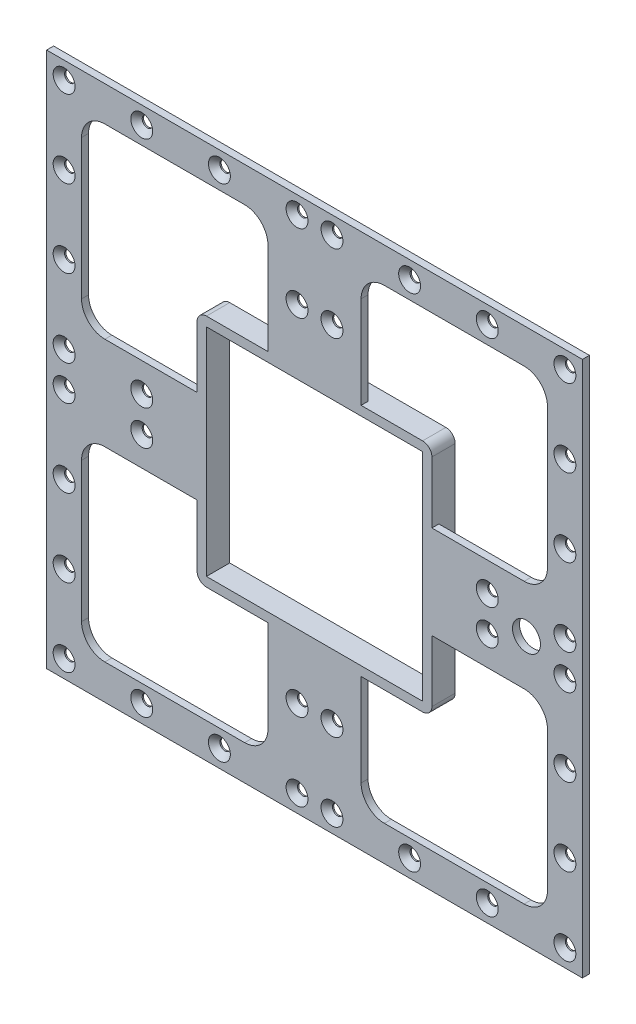
from build123d import *

# Parameters (mm, degrees)
SKETCH1_W              = 230
SKETCH1_H              = 230
BOSS_EXTRUDE1_DEPTH    = 3
SKETCH2_W              = 80
SKETCH2_H              = 80
CUT_EXTRUDE2_DEPTH     = 4
FILLET1_R              = 10
LPATTERN2_COUNT        = 2
LPATTERN2_PITCH        = 120
LPATTERN2_COUNT_DIR2   = 2
LPATTERN2_PITCH_DIR2   = 120
FILLET1_OF_LPATTERN2_R = 10
LPATTERN8_COUNT        = 4
LPATTERN8_PITCH        = 33.333333333
LPATTERN8_COUNT_DIR2   = 4
LPATTERN8_PITCH_DIR2   = 33.333333333
CUT_EXTRUDE3_REACH     = 5
SKETCH14_W             = 98
SKETCH14_H             = 98
SKETCH15_W             = 100.8
SKETCH15_H             = 100.8
SKETCH15_W_2           = 92.8
SKETCH15_H_2           = 92.8
BOSS_EXTRUDE2_DEPTH    = 10
FILLET2_R              = 4
CUT_EXTRUDE4_REACH     = 12
SKETCH16_R             = 6


with BuildPart() as part:
    # Sketch1 → Boss-Extrude1 (new body)
    with BuildSketch(Plane.XY):
        Rectangle(SKETCH1_W, SKETCH1_H)
    extrude(amount=BOSS_EXTRUDE1_DEPTH)

    # Sketch2 → Cut-Extrude2 (cut, through all)
    with BuildSketch(Plane.XY):
        with Locations((-60, 60)):
            Rectangle(SKETCH2_W, SKETCH2_H)
    cut_extrude2 = extrude(amount=CUT_EXTRUDE2_DEPTH, mode=Mode.SUBTRACT)

    # Fillet1
    fillet1_edges = [part.edges().sort_by_distance(p)[0] for p in [
        (-20, 20, 1.5),
        (-20, 100, 1.5),
        (-100, 100, 1.5),
        (-100, 20, 1.5),
    ]]
    fillet(fillet1_edges, radius=FILLET1_R)

    # LPattern2: Cut-Extrude2 2 × 2
    with Locations(*[(j * LPATTERN2_PITCH_DIR2, -i * LPATTERN2_PITCH, 0) for i in range(LPATTERN2_COUNT) for j in range(LPATTERN2_COUNT_DIR2) if (i, j) != (0, 0)]):
        add(cut_extrude2, mode=Mode.SUBTRACT)

    # Fillet1 of LPattern2
    fillet1_of_lpattern2_edges = [part.edges().sort_by_distance(p)[0] for p in [
        (100, 20, 1.5),
        (100, 100, 1.5),
        (20, 100, 1.5),
        (20, 20, 1.5),
        (-20, -100, 1.5),
        (-20, -20, 1.5),
        (-100, -20, 1.5),
        (-100, -100, 1.5),
        (100, -100, 1.5),
        (100, -20, 1.5),
        (20, -20, 1.5),
        (20, -100, 1.5),
    ]]
    fillet(fillet1_of_lpattern2_edges, radius=FILLET1_OF_LPATTERN2_R)

    # Sketch12 → CSK for M4 Flat Head Machine Screw4 (revolve, cut)
    with BuildSketch(Plane(origin=(-107.5, 107.5, 3), x_dir=(0, -1, 0), z_dir=(1, 0, 0))):
        Polygon((0, 0), (0, 3), (2.25, 3), (2.25, 2.45), (4.7, 0), align=None)
    csk_for_m4_flat_head_machine_screw4 = revolve(axis=Axis((-107.5, 107.5, 9.35), (0, 0, -1)), mode=Mode.SUBTRACT)

    # LPattern8: CSK for M4 Flat Head Machine Screw4 4 × 4, 4 skipped
    with Locations(*[(i * LPATTERN8_PITCH, -j * LPATTERN8_PITCH_DIR2, 0) for i in range(LPATTERN8_COUNT) for j in range(LPATTERN8_COUNT_DIR2) if (i, j) not in ((0, 0), (1, 1), (1, 2), (2, 1), (2, 2))]):
        add(csk_for_m4_flat_head_machine_screw4, mode=Mode.SUBTRACT)

    # Mirror1: CSK for M4 Flat Head Machine Screw4 across plane
    add(csk_for_m4_flat_head_machine_screw4.mirror(Plane(origin=(0, 0, 0), x_dir=(0, 0, 1), z_dir=(1, 0, 0))), mode=Mode.SUBTRACT)

    # Mirror1 copy 1 sketch → Mirror1 copy 1 (revolve, cut)
    with BuildSketch(Plane(origin=(107.5, 74.166666667, 3), x_dir=(0, -1, 0), z_dir=(-1, 0, 0))):
        Polygon((0, 0), (0, -3), (2.25, -3), (2.25, -2.45), (4.7, 0), align=None)
    revolve(axis=Axis((107.5, 74.166666667, 9.35), (0, 0, 1)), mode=Mode.SUBTRACT)

    # Mirror1 copy 2 sketch → Mirror1 copy 2 (revolve, cut)
    with BuildSketch(Plane(origin=(107.5, 40.833333333, 3), x_dir=(0, -1, 0), z_dir=(-1, 0, 0))):
        Polygon((0, 0), (0, -3), (2.25, -3), (2.25, -2.45), (4.7, 0), align=None)
    revolve(axis=Axis((107.5, 40.833333333, 9.35), (0, 0, 1)), mode=Mode.SUBTRACT)

    # Mirror1 copy 3 sketch → Mirror1 copy 3 (revolve, cut)
    with BuildSketch(Plane(origin=(107.5, 7.5, 3), x_dir=(0, -1, 0), z_dir=(-1, 0, 0))):
        Polygon((0, 0), (0, -3), (2.25, -3), (2.25, -2.45), (4.7, 0), align=None)
    revolve(axis=Axis((107.5, 7.5, 9.35), (0, 0, 1)), mode=Mode.SUBTRACT)

    # Mirror1 copy 4 sketch → Mirror1 copy 4 (revolve, cut)
    with BuildSketch(Plane(origin=(74.166666667, 107.5, 3), x_dir=(0, -1, 0), z_dir=(-1, 0, 0))):
        Polygon((0, 0), (0, -3), (2.25, -3), (2.25, -2.45), (4.7, 0), align=None)
    revolve(axis=Axis((74.166666667, 107.5, 9.35), (0, 0, 1)), mode=Mode.SUBTRACT)

    # Mirror1 copy 5 sketch → Mirror1 copy 5 (revolve, cut)
    with BuildSketch(Plane(origin=(74.166666667, 7.5, 3), x_dir=(0, -1, 0), z_dir=(-1, 0, 0))):
        Polygon((0, 0), (0, -3), (2.25, -3), (2.25, -2.45), (4.7, 0), align=None)
    revolve(axis=Axis((74.166666667, 7.5, 9.35), (0, 0, 1)), mode=Mode.SUBTRACT)

    # Mirror1 copy 6 sketch → Mirror1 copy 6 (revolve, cut)
    with BuildSketch(Plane(origin=(40.833333333, 107.5, 3), x_dir=(0, -1, 0), z_dir=(-1, 0, 0))):
        Polygon((0, 0), (0, -3), (2.25, -3), (2.25, -2.45), (4.7, 0), align=None)
    revolve(axis=Axis((40.833333333, 107.5, 9.35), (0, 0, 1)), mode=Mode.SUBTRACT)

    # Mirror1 copy 7 sketch → Mirror1 copy 7 (revolve, cut)
    with BuildSketch(Plane(origin=(40.833333333, 7.5, 3), x_dir=(0, -1, 0), z_dir=(-1, 0, 0))):
        Polygon((0, 0), (0, -3), (2.25, -3), (2.25, -2.45), (4.7, 0), align=None)
    revolve(axis=Axis((40.833333333, 7.5, 9.35), (0, 0, 1)), mode=Mode.SUBTRACT)

    # Mirror1 copy 8 sketch → Mirror1 copy 8 (revolve, cut)
    with BuildSketch(Plane(origin=(7.5, 107.5, 3), x_dir=(0, -1, 0), z_dir=(-1, 0, 0))):
        Polygon((0, 0), (0, -3), (2.25, -3), (2.25, -2.45), (4.7, 0), align=None)
    revolve(axis=Axis((7.5, 107.5, 9.35), (0, 0, 1)), mode=Mode.SUBTRACT)

    # Mirror1 copy 9 sketch → Mirror1 copy 9 (revolve, cut)
    with BuildSketch(Plane(origin=(7.5, 74.166666667, 3), x_dir=(0, -1, 0), z_dir=(-1, 0, 0))):
        Polygon((0, 0), (0, -3), (2.25, -3), (2.25, -2.45), (4.7, 0), align=None)
    revolve(axis=Axis((7.5, 74.166666667, 9.35), (0, 0, 1)), mode=Mode.SUBTRACT)

    # Mirror1 copy 10 sketch → Mirror1 copy 10 (revolve, cut)
    with BuildSketch(Plane(origin=(7.5, 40.833333333, 3), x_dir=(0, -1, 0), z_dir=(-1, 0, 0))):
        Polygon((0, 0), (0, -3), (2.25, -3), (2.25, -2.45), (4.7, 0), align=None)
    revolve(axis=Axis((7.5, 40.833333333, 9.35), (0, 0, 1)), mode=Mode.SUBTRACT)

    # Mirror1 copy 11 sketch → Mirror1 copy 11 (revolve, cut)
    with BuildSketch(Plane(origin=(7.5, 7.5, 3), x_dir=(0, -1, 0), z_dir=(-1, 0, 0))):
        Polygon((0, 0), (0, -3), (2.25, -3), (2.25, -2.45), (4.7, 0), align=None)
    revolve(axis=Axis((7.5, 7.5, 9.35), (0, 0, 1)), mode=Mode.SUBTRACT)

    # Mirror1 at the second plane: CSK for M4 Flat Head Machine Screw4 across plane
    add(csk_for_m4_flat_head_machine_screw4.mirror(Plane.ZX), mode=Mode.SUBTRACT)

    # Mirror1 at the second plane copy 1 sketc → Mirror1 at the second plane copy 1 (revolve, cut)
    with BuildSketch(Plane(origin=(-107.5, -74.166666667, 3), x_dir=(0, 1, 0), z_dir=(1, 0, 0))):
        Polygon((0, 0), (0, -3), (2.25, -3), (2.25, -2.45), (4.7, 0), align=None)
    revolve(axis=Axis((-107.5, -74.166666667, 9.35), (0, 0, 1)), mode=Mode.SUBTRACT)

    # Mirror1 at the second plane copy 2 sketc → Mirror1 at the second plane copy 2 (revolve, cut)
    with BuildSketch(Plane(origin=(-107.5, -40.833333333, 3), x_dir=(0, 1, 0), z_dir=(1, 0, 0))):
        Polygon((0, 0), (0, -3), (2.25, -3), (2.25, -2.45), (4.7, 0), align=None)
    revolve(axis=Axis((-107.5, -40.833333333, 9.35), (0, 0, 1)), mode=Mode.SUBTRACT)

    # Mirror1 at the second plane copy 3 sketc → Mirror1 at the second plane copy 3 (revolve, cut)
    with BuildSketch(Plane(origin=(-107.5, -7.5, 3), x_dir=(0, 1, 0), z_dir=(1, 0, 0))):
        Polygon((0, 0), (0, -3), (2.25, -3), (2.25, -2.45), (4.7, 0), align=None)
    revolve(axis=Axis((-107.5, -7.5, 9.35), (0, 0, 1)), mode=Mode.SUBTRACT)

    # Mirror1 at the second plane copy 4 sketc → Mirror1 at the second plane copy 4 (revolve, cut)
    with BuildSketch(Plane(origin=(-74.166666667, -107.5, 3), x_dir=(0, 1, 0), z_dir=(1, 0, 0))):
        Polygon((0, 0), (0, -3), (2.25, -3), (2.25, -2.45), (4.7, 0), align=None)
    revolve(axis=Axis((-74.166666667, -107.5, 9.35), (0, 0, 1)), mode=Mode.SUBTRACT)

    # Mirror1 at the second plane copy 5 sketc → Mirror1 at the second plane copy 5 (revolve, cut)
    with BuildSketch(Plane(origin=(-74.166666667, -7.5, 3), x_dir=(0, 1, 0), z_dir=(1, 0, 0))):
        Polygon((0, 0), (0, -3), (2.25, -3), (2.25, -2.45), (4.7, 0), align=None)
    revolve(axis=Axis((-74.166666667, -7.5, 9.35), (0, 0, 1)), mode=Mode.SUBTRACT)

    # Mirror1 at the second plane copy 6 sketc → Mirror1 at the second plane copy 6 (revolve, cut)
    with BuildSketch(Plane(origin=(-40.833333333, -107.5, 3), x_dir=(0, 1, 0), z_dir=(1, 0, 0))):
        Polygon((0, 0), (0, -3), (2.25, -3), (2.25, -2.45), (4.7, 0), align=None)
    revolve(axis=Axis((-40.833333333, -107.5, 9.35), (0, 0, 1)), mode=Mode.SUBTRACT)

    # Mirror1 at the second plane copy 7 sketc → Mirror1 at the second plane copy 7 (revolve, cut)
    with BuildSketch(Plane(origin=(-40.833333333, -7.5, 3), x_dir=(0, 1, 0), z_dir=(1, 0, 0))):
        Polygon((0, 0), (0, -3), (2.25, -3), (2.25, -2.45), (4.7, 0), align=None)
    revolve(axis=Axis((-40.833333333, -7.5, 9.35), (0, 0, 1)), mode=Mode.SUBTRACT)

    # Mirror1 at the second plane copy 8 sketc → Mirror1 at the second plane copy 8 (revolve, cut)
    with BuildSketch(Plane(origin=(-7.5, -107.5, 3), x_dir=(0, 1, 0), z_dir=(1, 0, 0))):
        Polygon((0, 0), (0, -3), (2.25, -3), (2.25, -2.45), (4.7, 0), align=None)
    revolve(axis=Axis((-7.5, -107.5, 9.35), (0, 0, 1)), mode=Mode.SUBTRACT)

    # Mirror1 at the second plane copy 9 sketc → Mirror1 at the second plane copy 9 (revolve, cut)
    with BuildSketch(Plane(origin=(-7.5, -74.166666667, 3), x_dir=(0, 1, 0), z_dir=(1, 0, 0))):
        Polygon((0, 0), (0, -3), (2.25, -3), (2.25, -2.45), (4.7, 0), align=None)
    revolve(axis=Axis((-7.5, -74.166666667, 9.35), (0, 0, 1)), mode=Mode.SUBTRACT)

    # Mirror1 at the second plane copy 10 sket → Mirror1 at the second plane copy 10 (revolve, cut)
    with BuildSketch(Plane(origin=(-7.5, -40.833333333, 3), x_dir=(0, 1, 0), z_dir=(1, 0, 0))):
        Polygon((0, 0), (0, -3), (2.25, -3), (2.25, -2.45), (4.7, 0), align=None)
    revolve(axis=Axis((-7.5, -40.833333333, 9.35), (0, 0, 1)), mode=Mode.SUBTRACT)

    # Mirror1 at the second plane copy 11 sket → Mirror1 at the second plane copy 11 (revolve, cut)
    with BuildSketch(Plane(origin=(-7.5, -7.5, 3), x_dir=(0, 1, 0), z_dir=(1, 0, 0))):
        Polygon((0, 0), (0, -3), (2.25, -3), (2.25, -2.45), (4.7, 0), align=None)
    revolve(axis=Axis((-7.5, -7.5, 9.35), (0, 0, 1)), mode=Mode.SUBTRACT)

    # Mirror1 at the second plane copy 12 sket → Mirror1 at the second plane copy 12 (revolve, cut)
    with BuildSketch(Plane(origin=(107.5, -107.5, 3), x_dir=(0, 1, 0), z_dir=(-1, 0, 0))):
        Polygon((0, 0), (0, 3), (2.25, 3), (2.25, 2.45), (4.7, 0), align=None)
    revolve(axis=Axis((107.5, -107.5, 9.35), (0, 0, -1)), mode=Mode.SUBTRACT)

    # Mirror1 at the second plane copy 13 sket → Mirror1 at the second plane copy 13 (revolve, cut)
    with BuildSketch(Plane(origin=(107.5, -74.166666667, 3), x_dir=(0, 1, 0), z_dir=(-1, 0, 0))):
        Polygon((0, 0), (0, 3), (2.25, 3), (2.25, 2.45), (4.7, 0), align=None)
    revolve(axis=Axis((107.5, -74.166666667, 9.35), (0, 0, -1)), mode=Mode.SUBTRACT)

    # Mirror1 at the second plane copy 14 sket → Mirror1 at the second plane copy 14 (revolve, cut)
    with BuildSketch(Plane(origin=(107.5, -40.833333333, 3), x_dir=(0, 1, 0), z_dir=(-1, 0, 0))):
        Polygon((0, 0), (0, 3), (2.25, 3), (2.25, 2.45), (4.7, 0), align=None)
    revolve(axis=Axis((107.5, -40.833333333, 9.35), (0, 0, -1)), mode=Mode.SUBTRACT)

    # Mirror1 at the second plane copy 15 sket → Mirror1 at the second plane copy 15 (revolve, cut)
    with BuildSketch(Plane(origin=(107.5, -7.5, 3), x_dir=(0, 1, 0), z_dir=(-1, 0, 0))):
        Polygon((0, 0), (0, 3), (2.25, 3), (2.25, 2.45), (4.7, 0), align=None)
    revolve(axis=Axis((107.5, -7.5, 9.35), (0, 0, -1)), mode=Mode.SUBTRACT)

    # Mirror1 at the second plane copy 16 sket → Mirror1 at the second plane copy 16 (revolve, cut)
    with BuildSketch(Plane(origin=(74.166666667, -107.5, 3), x_dir=(0, 1, 0), z_dir=(-1, 0, 0))):
        Polygon((0, 0), (0, 3), (2.25, 3), (2.25, 2.45), (4.7, 0), align=None)
    revolve(axis=Axis((74.166666667, -107.5, 9.35), (0, 0, -1)), mode=Mode.SUBTRACT)

    # Mirror1 at the second plane copy 17 sket → Mirror1 at the second plane copy 17 (revolve, cut)
    with BuildSketch(Plane(origin=(74.166666667, -7.5, 3), x_dir=(0, 1, 0), z_dir=(-1, 0, 0))):
        Polygon((0, 0), (0, 3), (2.25, 3), (2.25, 2.45), (4.7, 0), align=None)
    revolve(axis=Axis((74.166666667, -7.5, 9.35), (0, 0, -1)), mode=Mode.SUBTRACT)

    # Mirror1 at the second plane copy 18 sket → Mirror1 at the second plane copy 18 (revolve, cut)
    with BuildSketch(Plane(origin=(40.833333333, -107.5, 3), x_dir=(0, 1, 0), z_dir=(-1, 0, 0))):
        Polygon((0, 0), (0, 3), (2.25, 3), (2.25, 2.45), (4.7, 0), align=None)
    revolve(axis=Axis((40.833333333, -107.5, 9.35), (0, 0, -1)), mode=Mode.SUBTRACT)

    # Mirror1 at the second plane copy 19 sket → Mirror1 at the second plane copy 19 (revolve, cut)
    with BuildSketch(Plane(origin=(40.833333333, -7.5, 3), x_dir=(0, 1, 0), z_dir=(-1, 0, 0))):
        Polygon((0, 0), (0, 3), (2.25, 3), (2.25, 2.45), (4.7, 0), align=None)
    revolve(axis=Axis((40.833333333, -7.5, 9.35), (0, 0, -1)), mode=Mode.SUBTRACT)

    # Mirror1 at the second plane copy 20 sket → Mirror1 at the second plane copy 20 (revolve, cut)
    with BuildSketch(Plane(origin=(7.5, -107.5, 3), x_dir=(0, 1, 0), z_dir=(-1, 0, 0))):
        Polygon((0, 0), (0, 3), (2.25, 3), (2.25, 2.45), (4.7, 0), align=None)
    revolve(axis=Axis((7.5, -107.5, 9.35), (0, 0, -1)), mode=Mode.SUBTRACT)

    # Mirror1 at the second plane copy 21 sket → Mirror1 at the second plane copy 21 (revolve, cut)
    with BuildSketch(Plane(origin=(7.5, -74.166666667, 3), x_dir=(0, 1, 0), z_dir=(-1, 0, 0))):
        Polygon((0, 0), (0, 3), (2.25, 3), (2.25, 2.45), (4.7, 0), align=None)
    revolve(axis=Axis((7.5, -74.166666667, 9.35), (0, 0, -1)), mode=Mode.SUBTRACT)

    # Mirror1 at the second plane copy 22 sket → Mirror1 at the second plane copy 22 (revolve, cut)
    with BuildSketch(Plane(origin=(7.5, -40.833333333, 3), x_dir=(0, 1, 0), z_dir=(-1, 0, 0))):
        Polygon((0, 0), (0, 3), (2.25, 3), (2.25, 2.45), (4.7, 0), align=None)
    revolve(axis=Axis((7.5, -40.833333333, 9.35), (0, 0, -1)), mode=Mode.SUBTRACT)

    # Mirror1 at the second plane copy 23 sket → Mirror1 at the second plane copy 23 (revolve, cut)
    with BuildSketch(Plane(origin=(7.5, -7.5, 3), x_dir=(0, 1, 0), z_dir=(-1, 0, 0))):
        Polygon((0, 0), (0, 3), (2.25, 3), (2.25, 2.45), (4.7, 0), align=None)
    revolve(axis=Axis((7.5, -7.5, 9.35), (0, 0, -1)), mode=Mode.SUBTRACT)

    # Sketch14 → Cut-Extrude3 (cut, up to next)
    with BuildSketch(Plane.XY.offset(3), mode=Mode.PRIVATE) as cut_extrude3_sk1:
        Rectangle(SKETCH14_W, SKETCH14_H)
    cut_extrude3_tool1 = extrude(cut_extrude3_sk1.sketch, amount=-CUT_EXTRUDE3_REACH, mode=Mode.PRIVATE) & part.part
    add(cut_extrude3_tool1.solids().sort_by_distance((0, 0, 3))[0], mode=Mode.SUBTRACT)

    # Sketch15 → Boss-Extrude2 (add)
    with BuildSketch(Plane.XY.offset(3)):
        Rectangle(SKETCH15_W, SKETCH15_H)
        Rectangle(SKETCH15_W_2, SKETCH15_H_2, mode=Mode.SUBTRACT)
    extrude(amount=-BOSS_EXTRUDE2_DEPTH)

    # Fillet2
    fillet2_edges = [part.edges().sort_by_distance(p)[0] for p in [
        (50.4, 50.4, -2),
        (50.4, -50.4, -2),
        (-50.4, -50.4, -2),
        (-50.4, 50.4, -2),
    ]]
    fillet(fillet2_edges, radius=FILLET2_R)

    # Sketch16 → Cut-Extrude4 (cut, up to next)
    with BuildSketch(Plane.XY.offset(3), mode=Mode.PRIVATE) as cut_extrude4_sk1:
        with Locations((91, 0)):
            Circle(SKETCH16_R)
    cut_extrude4_tool1 = extrude(cut_extrude4_sk1.sketch, amount=-CUT_EXTRUDE4_REACH, mode=Mode.PRIVATE) & part.part
    add(cut_extrude4_tool1.solids().sort_by_distance((91, 0, 3))[0], mode=Mode.SUBTRACT)


solid = part.part
